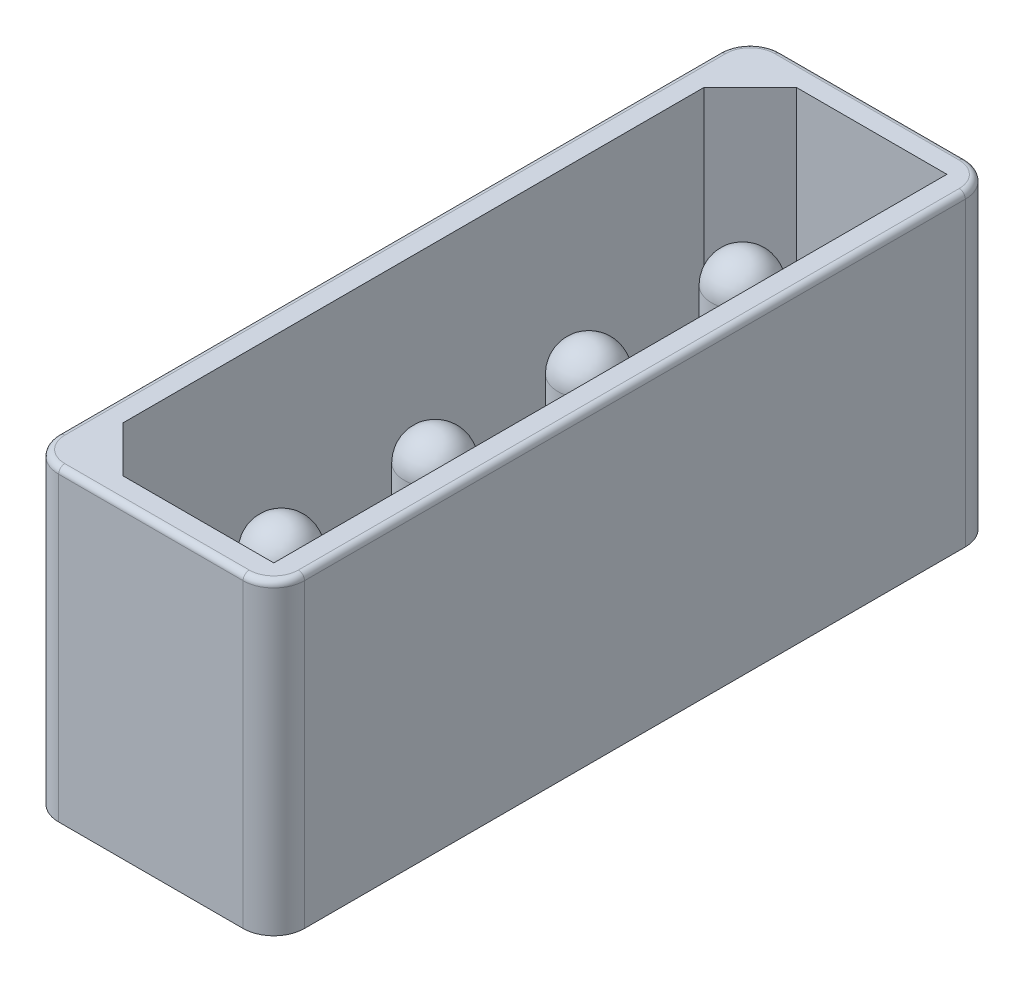
from build123d import *

# Parameters (mm, degrees)
CROQUIS1_W            = 8
CROQUIS1_H            = 23.5
CROQUIS1_W_2          = 6.4
CROQUIS1_H_2          = 21.9
EXTRUIR1_DEPTH        = 11
CHAFL_N1_SIZE         = 1.5
REDONDEO1_R           = 1
REDONDEO2_R           = 0.2
EXTRUIR2_DEPTH        = 1
CROQUIS3_R            = 1
EXTRUIR4_DEPTH        = 8
EXTRUIR4_2_DEPTH      = 8
EXTRUIR4_3_DEPTH      = 8
EXTRUIR4_4_DEPTH      = 8
REDONDEO3_R           = 1
REDONDEO4_R           = 1
REDONDEO5_R           = 1
REDONDEO6_R           = 1
CROQUIS4_W            = 24.783427495
CROQUIS4_H            = 1.401443817
CORTAR_EXTRUIR1_DEPTH = 14
EXTRUIR5_DEPTH        = 0.5


with BuildPart() as part:
    # Croquis1 → Extruir1 (new body)
    with BuildSketch(Plane(origin=(0, 0, 0), x_dir=(1, 0, 0), z_dir=(0, 1, 0))):
        Rectangle(CROQUIS1_W, CROQUIS1_H)
        Rectangle(CROQUIS1_W_2, CROQUIS1_H_2, mode=Mode.SUBTRACT)
    extrude(amount=EXTRUIR1_DEPTH)

    # Chaflán1
    chafl_n1_edges = [part.edges().sort_by_distance(p)[0] for p in [
        (-3.2, 5.5, -10.95),
        (-3.2, 5.5, 10.95),
    ]]
    chamfer(chafl_n1_edges, length=CHAFL_N1_SIZE)

    # Redondeo1
    redondeo1_edges = [part.edges().sort_by_distance(p)[0] for p in [
        (-4, 5.5, -11.75),
        (4, 5.5, -11.75),
        (4, 5.5, 11.75),
        (-4, 5.5, 11.75),
    ]]
    fillet(redondeo1_edges, radius=REDONDEO1_R)

    # Redondeo2
    redondeo2_edges = [part.edges().sort_by_distance(p)[0] for p in [
        (0, 11, 11.75),
        (-4, 11, 0),
        (4, 11, 0),
        (0, 11, -11.75),
        (-3.707106781, 11, -11.457106781),
        (3.707106781, 11, -11.457106781),
        (3.707106781, 11, 11.457106781),
        (-3.707106781, 11, 11.457106781),
    ]]
    fillet(redondeo2_edges, radius=REDONDEO2_R)

    # Croquis2 → Extruir2 (add)
    with BuildSketch(Plane.XZ):
        with BuildLine():
            Line((3, 11.75), (-3, 11.75))
            ThreePointArc((-3, 11.75), (-3.707106781, 11.457106781), (-4, 10.75))
            Line((-4, 10.75), (-4, -10.75))
            ThreePointArc((-4, -10.75), (-3.707106781, -11.457106781), (-3, -11.75))
            Line((-3, -11.75), (3, -11.75))
            ThreePointArc((3, -11.75), (3.707106781, -11.457106781), (4, -10.75))
            Line((4, -10.75), (4, 10.75))
            ThreePointArc((4, 10.75), (3.707106781, 11.457106781), (3, 11.75))
        make_face()
    extrude(amount=-EXTRUIR2_DEPTH)

    # Croquis4 → Cortar-Extruir1 (cut)
    with BuildSketch(Plane.ZY.offset(4)):
        with Locations((-0.0368801, 0.299278091)):
            Rectangle(CROQUIS4_W, CROQUIS4_H)
    extrude(amount=-CORTAR_EXTRUIR1_DEPTH, mode=Mode.SUBTRACT)


with BuildPart() as body_2:
    # Croquis3 → Extruir4 (new body)
    with BuildSketch(Plane(origin=(0, 1, 0), x_dir=(-1, 0, 0), z_dir=(0, 1, 0))):
        with Locations((0, 7.5)):
            Circle(CROQUIS3_R)
    extrude(amount=EXTRUIR4_DEPTH)

    # Redondeo6
    redondeo6_edges = [body_2.edges().sort_by_distance(p)[0] for p in [
        (1, 9, 7.5),
    ]]
    fillet(redondeo6_edges, radius=REDONDEO6_R)


with BuildPart() as body_3:
    # Croquis3 → Extruir4 2 (new body)
    with BuildSketch(Plane(origin=(0, 1, 0), x_dir=(-1, 0, 0), z_dir=(0, 1, 0))):
        with Locations((0, 2.5)):
            Circle(CROQUIS3_R)
    extrude(amount=EXTRUIR4_2_DEPTH)

    # Redondeo5
    redondeo5_edges = [body_3.edges().sort_by_distance(p)[0] for p in [
        (1, 9, 2.5),
    ]]
    fillet(redondeo5_edges, radius=REDONDEO5_R)


with BuildPart() as body_4:
    # Croquis3 → Extruir4 3 (new body)
    with BuildSketch(Plane(origin=(0, 1, 0), x_dir=(-1, 0, 0), z_dir=(0, 1, 0))):
        with Locations((0, -2.5)):
            Circle(CROQUIS3_R)
    extrude(amount=EXTRUIR4_3_DEPTH)

    # Redondeo4
    redondeo4_edges = [body_4.edges().sort_by_distance(p)[0] for p in [
        (1, 9, -2.5),
    ]]
    fillet(redondeo4_edges, radius=REDONDEO4_R)


with BuildPart() as body_5:
    # Croquis3 → Extruir4 4 (new body)
    with BuildSketch(Plane(origin=(0, 1, 0), x_dir=(-1, 0, 0), z_dir=(0, 1, 0))):
        with Locations((0, -7.5)):
            Circle(CROQUIS3_R)
    extrude(amount=EXTRUIR4_4_DEPTH)

    # Redondeo3
    redondeo3_edges = [body_5.edges().sort_by_distance(p)[0] for p in [
        (1, 9, -7.5),
    ]]
    fillet(redondeo3_edges, radius=REDONDEO3_R)


with BuildPart() as body_6:
    # Croquis5 → Extruir5 (new body)
    with BuildSketch(Plane.XZ.offset(-1)):
        with BuildLine():
            Line((-4, 10.75), (-4, -10.75))
            ThreePointArc((-4, -10.75), (-3.707106781, -11.457106781), (-3, -11.75))
            Line((-3, -11.75), (3, -11.75))
            ThreePointArc((3, -11.75), (3.707106781, -11.457106781), (4, -10.75))
            Line((4, -10.75), (4, 10.75))
            ThreePointArc((4, 10.75), (3.707106781, 11.457106781), (3, 11.75))
            Line((3, 11.75), (-3, 11.75))
            ThreePointArc((-3, 11.75), (-3.707106781, 11.457106781), (-4, 10.75))
        make_face()
    extrude(amount=-EXTRUIR5_DEPTH)

    # Combinar1: union part
    add(part.part)


solid = Compound([body_2.part, body_3.part, body_4.part, body_5.part, body_6.part])
